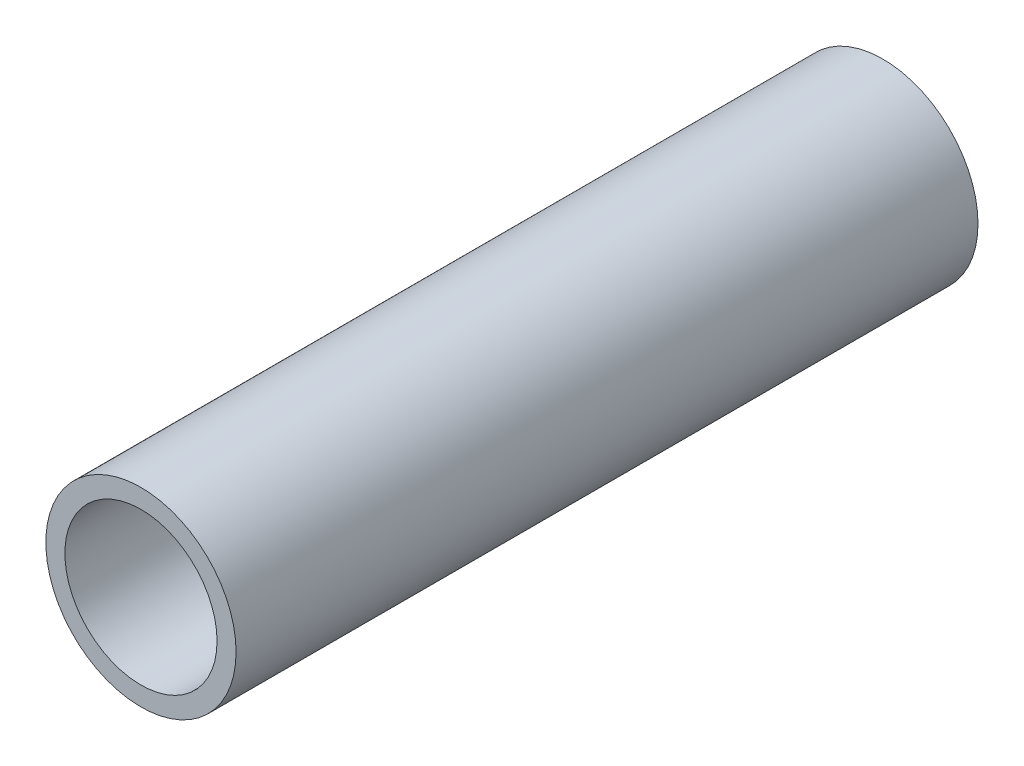
from build123d import *

# Parameters (mm, degrees)
ESQUISSE1_R        = 10
ESQUISSE1_R_2      = 8
BOSS_EXTRU_1_DEPTH = 39


with BuildPart() as part:
    # Esquisse1 → Boss.-Extru.1 (new body, symmetric)
    with BuildSketch(Plane.XY):
        Circle(ESQUISSE1_R)
        Circle(ESQUISSE1_R_2, mode=Mode.SUBTRACT)
    extrude(amount=BOSS_EXTRU_1_DEPTH, both=True)


solid = part.part
